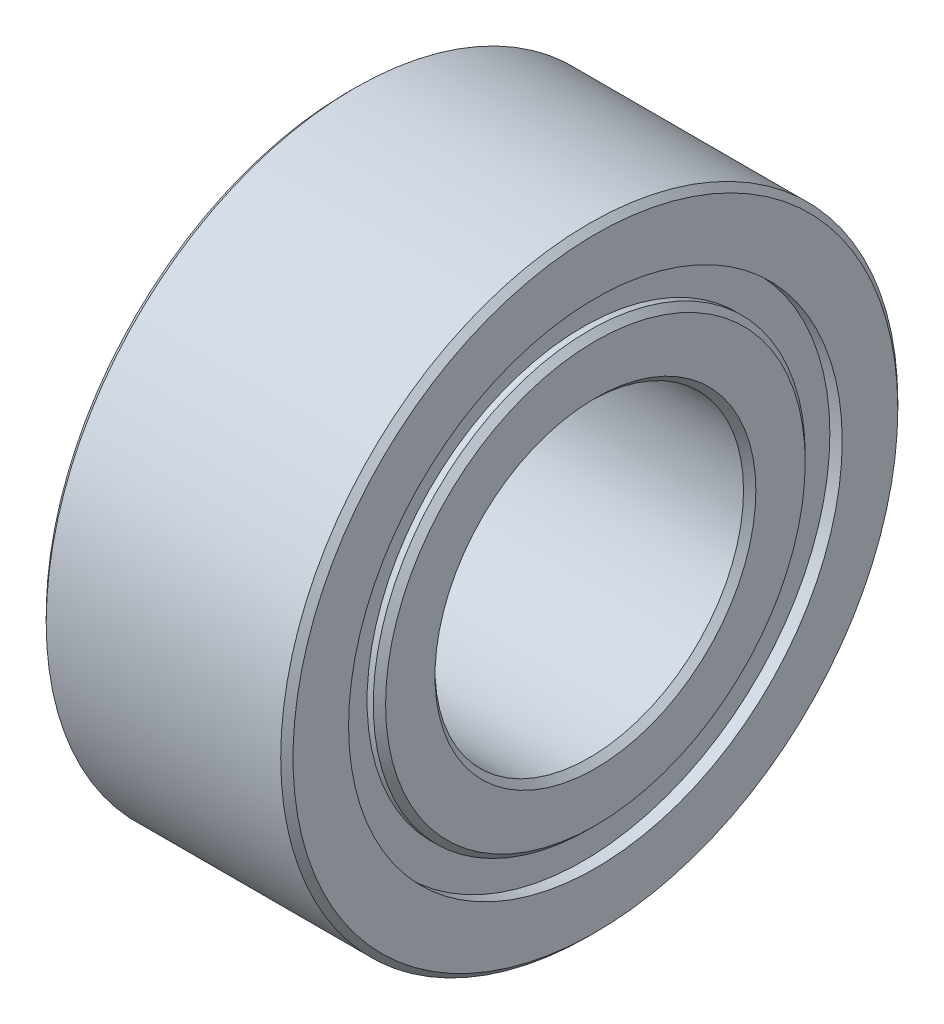
from build123d import *

# Parameters (mm, degrees)
SKETCH_1_R          = 5
SKETCH_1_R_2        = 2.5
EXTRUDE_1_DEPTH     = 4
SKETCH_2_R          = 3.999624375
SKETCH_2_R_2        = 3.5
CUT_EXTRUDE_1_DEPTH = 0.2
SKETCH_3_R          = 3.950876812
SKETCH_3_R_2        = 3.5
CUT_EXTRUDE_2_DEPTH = 0.2
CHAMFER_1_SIZE      = 0.1


with BuildPart() as part:
    # 草图1 → 凸台-拉伸1 (new body)
    with BuildSketch(Plane(origin=(0, 0, 0), x_dir=(0, 0, -1), z_dir=(1, 0, 0))):
        Circle(SKETCH_1_R)
        Circle(SKETCH_1_R_2, mode=Mode.SUBTRACT)
    extrude(amount=EXTRUDE_1_DEPTH)

    # 草图2 → 切除-拉伸1 (cut)
    with BuildSketch(Plane(origin=(4, 0, 0), x_dir=(0, 0, -1), z_dir=(1, 0, 0))):
        with Locations((-0.000375625, 0)):
            Circle(SKETCH_2_R)
        with Locations((-0.000375625, 0)):
            Circle(SKETCH_2_R_2, mode=Mode.SUBTRACT)
    extrude(amount=-CUT_EXTRUDE_1_DEPTH, mode=Mode.SUBTRACT)

    # 草图3 → 切除-拉伸2 (cut)
    with BuildSketch(Plane.ZY):
        with Locations((-0.049123188, 0)):
            Circle(SKETCH_3_R)
        with Locations((-0.049123188, 0)):
            Circle(SKETCH_3_R_2, mode=Mode.SUBTRACT)
    extrude(amount=-CUT_EXTRUDE_2_DEPTH, mode=Mode.SUBTRACT)

    # 倒角1
    chamfer_1_edges = [part.edges().sort_by_distance(p)[0] for p in [
        (4, 0, 3.500375625),
        (0, 0, 5),
        (0, 0, -4),
        (0, 0, -3.549123188),
        (4, 0, 5),
        (0, 0, 2.5),
        (4, 0, 2.5),
    ]]
    chamfer(chamfer_1_edges, length=CHAMFER_1_SIZE)


solid = part.part
